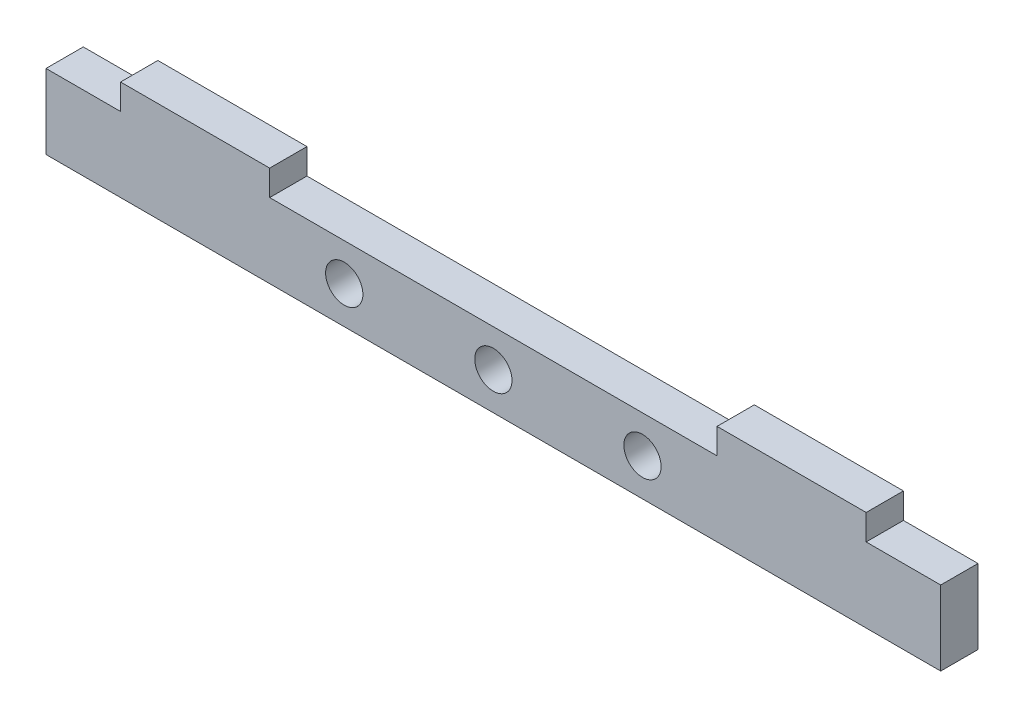
from build123d import *

# Parameters (mm, degrees)
SKETCH1_R           = 3.175
BOSS_EXTRUDE1_DEPTH = 6.35


with BuildPart() as part:
    # Sketch1 → Boss-Extrude1 (new body)
    with BuildSketch(Plane.XY):
        Polygon((38.1, 12.7), (114.3, 12.7), (114.3, 17.050166685), (139.7, 17.050166685), (139.7, 12.7), (152.4, 12.7), (152.4, 0), (0, 0), (0, 12.7), (12.7, 12.7), (12.7, 17.050166685), (38.1, 17.050166685), align=None)
        with Locations((50.8, 6.35)):
            Circle(SKETCH1_R, mode=Mode.SUBTRACT)
        with Locations((76.2, 6.35)):
            Circle(SKETCH1_R, mode=Mode.SUBTRACT)
        with Locations((101.6, 6.35)):
            Circle(SKETCH1_R, mode=Mode.SUBTRACT)
    extrude(amount=BOSS_EXTRUDE1_DEPTH)


solid = part.part
